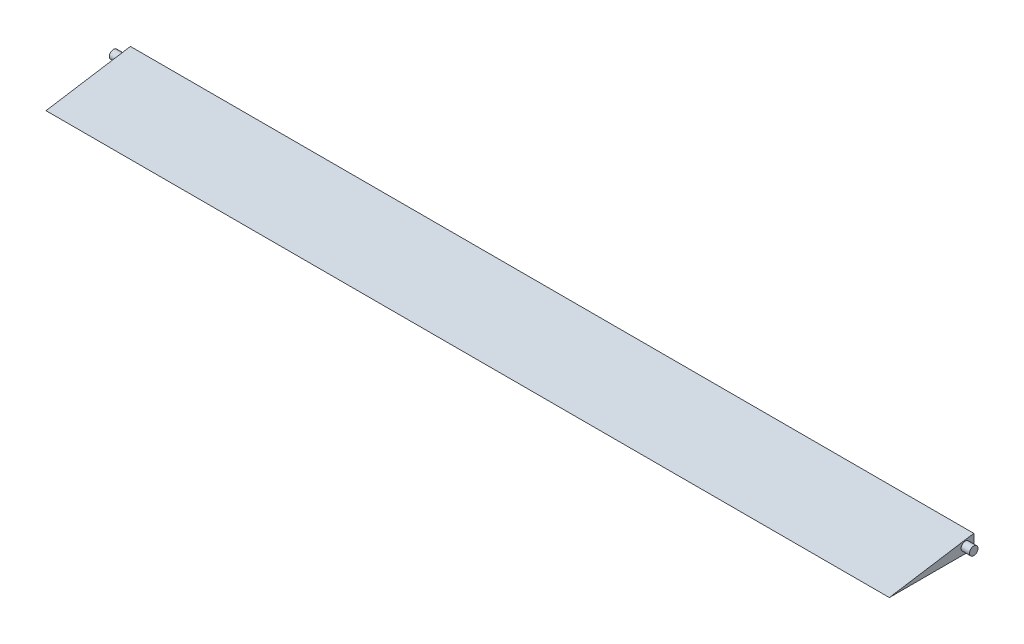
from build123d import *

# Parameters (mm, degrees)
Y_KSEKLIK_EKSTR_ZYON2_DEPTH = 499.5
IZIM4_R                     = 2.5
Y_KSEKLIK_EKSTR_ZYON3_DEPTH = 5
IZIM5_R                     = 2.5
Y_KSEKLIK_EKSTR_ZYON4_DEPTH = 5


with BuildPart() as part:
    # Çizim2 → Yükseklik-Ekstrüzyon2 (new body)
    with BuildSketch(Plane(origin=(0, 0, 0), x_dir=(0, 0, -1), z_dir=(1, 0, 0))):
        Polygon((-25, 0), (25, 0), (25, 7.96), align=None)
    extrude(amount=Y_KSEKLIK_EKSTR_ZYON2_DEPTH)

    # Çizim4 → Yükseklik-Ekstrüzyon3 (add)
    with BuildSketch(Plane(origin=(499.5, 0, 0), x_dir=(0, 0, -1), z_dir=(1, 0, 0))):
        with Locations((20, 3.98)):
            Circle(IZIM4_R)
    extrude(amount=Y_KSEKLIK_EKSTR_ZYON3_DEPTH)

    # Çizim5 → Yükseklik-Ekstrüzyon4 (add)
    with BuildSketch(Plane.ZY):
        with Locations((-20, 3.98)):
            Circle(IZIM5_R)
    extrude(amount=Y_KSEKLIK_EKSTR_ZYON4_DEPTH)


solid = part.part
